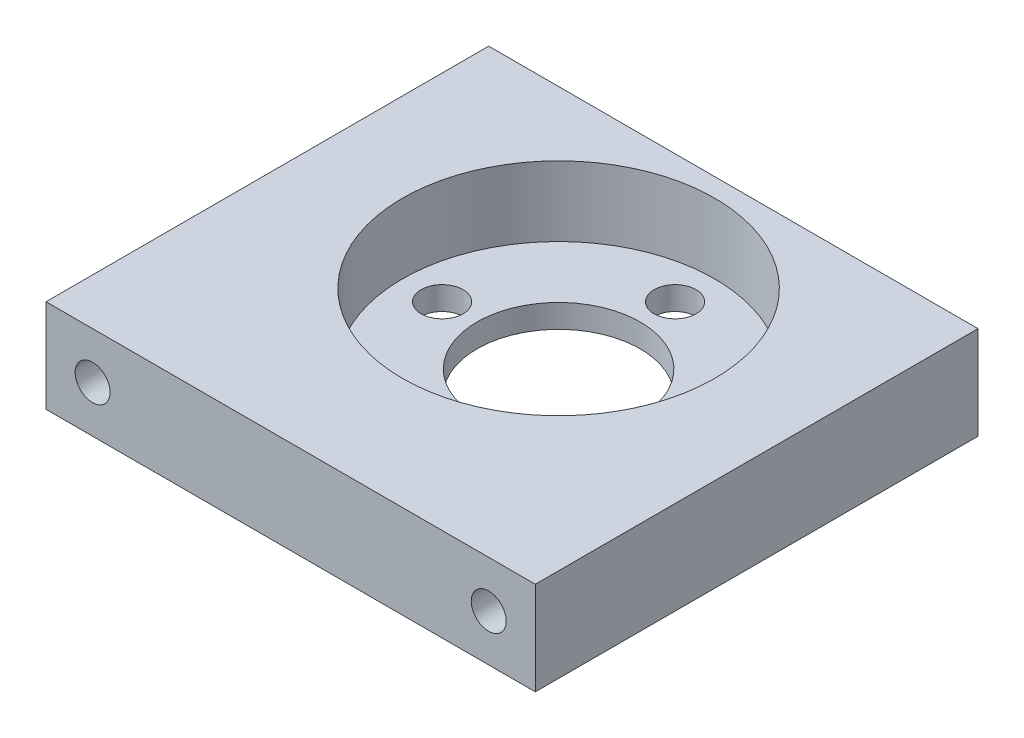
from build123d import *

# Parameters (mm, degrees)
ESQUISSE1_W             = 42
ESQUISSE1_H             = 46
BOSS_EXTRU_1_DEPTH      = 8
ESQUISSE2_R             = 13.4
ENL_V_MAT_EXTRU_1_DEPTH = 6
ESQUISSE3_R             = 7
ESQUISSE3_R_2           = 1.8
ENL_V_MAT_EXTRU_2_DEPTH = 3
ESQUISSE4_R             = 1.5
ENL_V_MAT_EXTRU_3_DEPTH = 47
ENL_V_MAT_EXTRU_4_REACH = 10
ESQUISSE5_W             = 42
ESQUISSE5_H             = 8


with BuildPart() as part:
    # Esquisse1 → Boss.-Extru.1 (new body)
    with BuildSketch(Plane(origin=(0, 0, 0), x_dir=(1, 0, 0), z_dir=(0, 1, 0))):
        with Locations((21, 23)):
            Rectangle(ESQUISSE1_W, ESQUISSE1_H)
    extrude(amount=BOSS_EXTRU_1_DEPTH)

    # Esquisse2 → Enlèv. mat.-Extru.1 (cut)
    with BuildSketch(Plane(origin=(0, 8, 0), x_dir=(1, 0, 0), z_dir=(0, 1, 0))):
        with Locations((21, 23)):
            Circle(ESQUISSE2_R)
    extrude(amount=-ENL_V_MAT_EXTRU_1_DEPTH, mode=Mode.SUBTRACT)

    # Esquisse3 → Enlèv. mat.-Extru.2 (cut, through all)
    with BuildSketch(Plane(origin=(0, 2, 0), x_dir=(1, 0, 0), z_dir=(0, 1, 0))):
        with Locations((21, 23)):
            Circle(ESQUISSE3_R)
        with Locations((21, 33)):
            Circle(ESQUISSE3_R_2)
        with Locations((31, 23)):
            Circle(ESQUISSE3_R_2)
        with Locations((21, 13)):
            Circle(ESQUISSE3_R_2)
        with Locations((11, 23)):
            Circle(ESQUISSE3_R_2)
    extrude(amount=-ENL_V_MAT_EXTRU_2_DEPTH, mode=Mode.SUBTRACT)

    # Esquisse4 → Enlèv. mat.-Extru.3 (cut, through all)
    with BuildSketch(Plane(origin=(0, 0, -46), x_dir=(-1, 0, 0), z_dir=(0, 0, -1))):
        with Locations((-38, 4)):
            Circle(ESQUISSE4_R)
        with Locations((-4, 4)):
            Circle(ESQUISSE4_R)
    extrude(amount=-ENL_V_MAT_EXTRU_3_DEPTH, mode=Mode.SUBTRACT)

    # Esquisse5 → Enlèv. mat.-Extru.4 (cut, up to next)
    with BuildSketch(Plane(origin=(0, 8, 0), x_dir=(1, 0, 0), z_dir=(0, 1, 0)), mode=Mode.PRIVATE) as enl_v_mat_extru_4_sk1:
        with Locations((21, 42)):
            Rectangle(ESQUISSE5_W, ESQUISSE5_H)
    enl_v_mat_extru_4_tool1 = extrude(enl_v_mat_extru_4_sk1.sketch, amount=-ENL_V_MAT_EXTRU_4_REACH, mode=Mode.PRIVATE) & part.part
    add(enl_v_mat_extru_4_tool1.solids().sort_by_distance((21, 8, -42))[0], mode=Mode.SUBTRACT)


solid = part.part
